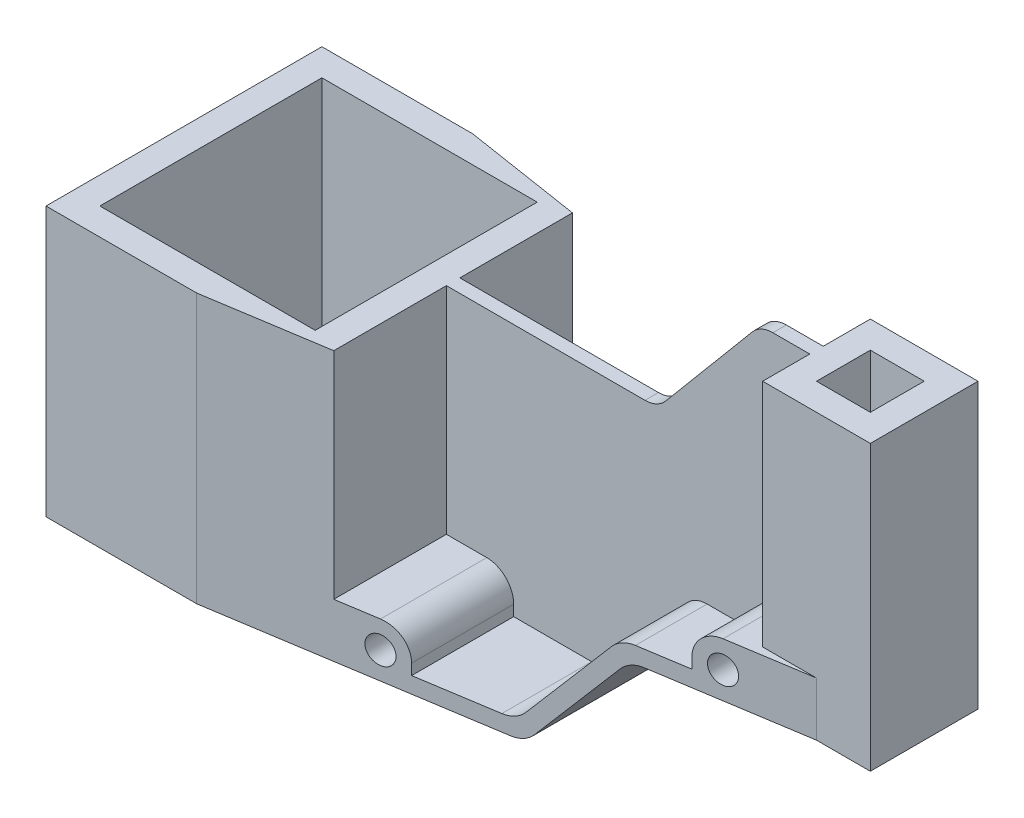
from build123d import *

# Parameters (mm, degrees)
ESQUISSE1_W                  = 50
ESQUISSE1_H                  = 100
BOSS_EXTRU_1_DEPTH           = 51.25
BOSS_EXTRU_2_DEPTH           = 45.5
BOSS_EXTRU_2_DEPTH_BACK      = 100
ESQUISSE2_W                  = 20
ESQUISSE2_H                  = 20
ESQUISSE2_3_W                = 80
ESQUISSE2_3_H                = 82.5
ENL_V_MAT_EXTRU_1_DEPTH      = 252.498633197
ENL_V_START                  = -2.5
ENL_V_MAT_EXTRU_3_DEPTH      = 271.303615262
ENL_V_START_2                = 2.5
ENL_V_MAT_EXTRU_4_DEPTH      = 271.303615262
ENL_V_MAT_EXTRU_5_DEPTH      = 273.803615262
ENL_V_MAT_EXTRU_5_DEPTH_BACK = 273.803615262
ESQUISSE1_6_R                = 5
ENL_V_START_3                = -20
ESQUISSE1_7_W                = 20
ESQUISSE1_7_H                = 85.5
ENL_V_MAT_EXTRU_6_DEPTH      = 31.25
ENL_V_START_4                = 20
ESQUISSE1_8_W                = 20
ESQUISSE1_8_H                = 85.5
ENL_V_MAT_EXTRU_7_DEPTH      = 31.25


with BuildPart() as part:
    # Esquisse1 → Boss.-Extru.1 (new, symmetric)
    with BuildSketch(Plane.XY):
        with Locations((-25, 50)):
            Rectangle(ESQUISSE1_W, ESQUISSE1_H)
    extrude(amount=BOSS_EXTRU_1_DEPTH, both=True)

    # Esquisse2 → Boss.-Extru.2 (add, two sides: drawn at the far end of the back side and taken through both)
    with BuildSketch(Plane(origin=(0, 100, 0), x_dir=(1, 0, 0), z_dir=(0, 1, 0)).offset(-BOSS_EXTRU_2_DEPTH_BACK)):
        Polygon((6, 51.25), (0, 51.25), (0, 41.25), (40, 41.25), (40, -41.25), (0, -41.25), (0, -51.25), (6, -51.25), (205, -20), (225, -20), (225, 20), (205, 20), align=None)
        with Locations((205, 0)):
            Rectangle(ESQUISSE2_W, ESQUISSE2_H, mode=Mode.SUBTRACT)
    extrude(amount=BOSS_EXTRU_2_DEPTH + BOSS_EXTRU_2_DEPTH_BACK)

    # Esquisse2_3 → Enl_v. mat.-Extru.1 (cut, through all)
    with BuildSketch(Plane(origin=(0, 100, 0), x_dir=(1, 0, 0), z_dir=(0, 1, 0))):
        Rectangle(ESQUISSE2_3_W, ESQUISSE2_3_H)
    extrude(amount=-ENL_V_MAT_EXTRU_1_DEPTH, mode=Mode.SUBTRACT)

    # Esquisse1_4 → Enl_v. mat.-Extru.3 (cut, through all)
    with BuildSketch(Plane.XY.offset(ENL_V_START)):
        with BuildLine():
            Line((50, 100), (50, 20))
            Line((50, 20), (65, 20))
            ThreePointArc((65, 20), (72.071067812, 17.071067812), (75, 10))
            Line((75, 10), (75, 6))
            Line((75, 6), (103.975092222, 6))
            ThreePointArc((103.975092222, 6), (108.20127484, 6.93692213), (111.635536654, 9.572123903))
            Line((111.635536654, 9.572123903), (139.204786201, 42.427876097))
            ThreePointArc((139.204786201, 42.427876097), (142.639048015, 45.06307787), (146.865230633, 46))
            Line((146.865230633, 46), (165, 46))
            Line((165, 46), (165, 50))
            ThreePointArc((165, 50), (167.928932188, 57.071067812), (175, 60))
            Line((175, 60), (185, 60))
            Line((185, 60), (185, 145.5))
            Line((185, 145.5), (171.285964092, 145.5))
            ThreePointArc((171.285964092, 145.5), (167.059781475, 144.56307787), (163.625519661, 141.927876097))
            Line((163.625519661, 141.927876097), (131.441222142, 103.572123903))
            ThreePointArc((131.441222142, 103.572123903), (128.006960328, 100.93692213), (123.780777711, 100))
            Line((123.780777711, 100), (50, 100))
        make_face()
    extrude(amount=-ENL_V_MAT_EXTRU_3_DEPTH, mode=Mode.SUBTRACT)

    # Esquisse1_5 → Enl_v. mat.-Extru.4 (cut, through all)
    with BuildSketch(Plane.XY.offset(ENL_V_START_2)):
        with BuildLine():
            Line((50, 100), (50, 20))
            Line((50, 20), (65, 20))
            ThreePointArc((65, 20), (72.071067812, 17.071067812), (75, 10))
            Line((75, 10), (75, 6))
            Line((75, 6), (103.975092222, 6))
            ThreePointArc((103.975092222, 6), (108.20127484, 6.93692213), (111.635536654, 9.572123903))
            Line((111.635536654, 9.572123903), (139.204786201, 42.427876097))
            ThreePointArc((139.204786201, 42.427876097), (142.639048015, 45.06307787), (146.865230633, 46))
            Line((146.865230633, 46), (165, 46))
            Line((165, 46), (165, 50))
            ThreePointArc((165, 50), (167.928932188, 57.071067812), (175, 60))
            Line((175, 60), (185, 60))
            Line((185, 60), (185, 145.5))
            Line((185, 145.5), (171.285964092, 145.5))
            ThreePointArc((171.285964092, 145.5), (167.059781475, 144.56307787), (163.625519661, 141.927876097))
            Line((163.625519661, 141.927876097), (131.441222142, 103.572123903))
            ThreePointArc((131.441222142, 103.572123903), (128.006960328, 100.93692213), (123.780777711, 100))
            Line((123.780777711, 100), (50, 100))
        make_face()
    extrude(amount=ENL_V_MAT_EXTRU_4_DEPTH, mode=Mode.SUBTRACT)

    # Esquisse1_6 → Enl_v. mat.-Extru.5 (cut, two sides: drawn at the far end of the back side and taken through both)
    with BuildSketch(Plane.XY.offset(-ENL_V_MAT_EXTRU_5_DEPTH_BACK)):
        with BuildLine():
            Line((0, 100), (123.780777711, 100))
            ThreePointArc((123.780777711, 100), (128.006960328, 100.93692213), (131.441222142, 103.572123903))
            Line((131.441222142, 103.572123903), (163.625519661, 141.927876097))
            ThreePointArc((163.625519661, 141.927876097), (167.059781475, 144.56307787), (171.285964092, 145.5))
            Line((171.285964092, 145.5), (0, 145.5))
            Line((0, 145.5), (0, 100))
        make_face()
        with BuildLine():
            ThreePointArc((114.433382603, 3.572123903), (110.999120789, 0.93692213), (106.772938171, 0))
            Line((106.772938171, 0), (225, 0))
            Line((225, 0), (225, 40))
            Line((225, 40), (149.663076582, 40))
            ThreePointArc((149.663076582, 40), (145.436893964, 39.06307787), (142.00263215, 36.427876097))
            Line((142.00263215, 36.427876097), (114.433382603, 3.572123903))
        make_face()
        with Locations((65, 10)):
            Circle(ESQUISSE1_6_R)
        with Locations((175, 50)):
            Circle(ESQUISSE1_6_R)
    extrude(amount=ENL_V_MAT_EXTRU_5_DEPTH + ENL_V_MAT_EXTRU_5_DEPTH_BACK, mode=Mode.SUBTRACT)

    # Esquisse1_7 → Enl_v. mat.-Extru.6 (cut)
    with BuildSketch(Plane.XY.offset(ENL_V_START_3)):
        with Locations((195, 102.75)):
            Rectangle(ESQUISSE1_7_W, ESQUISSE1_7_H)
    extrude(amount=-ENL_V_MAT_EXTRU_6_DEPTH, mode=Mode.SUBTRACT)

    # Esquisse1_8 → Enl_v. mat.-Extru.7 (cut)
    with BuildSketch(Plane.XY.offset(ENL_V_START_4)):
        with Locations((195, 102.75)):
            Rectangle(ESQUISSE1_8_W, ESQUISSE1_8_H)
    extrude(amount=ENL_V_MAT_EXTRU_7_DEPTH, mode=Mode.SUBTRACT)


solid = part.part
